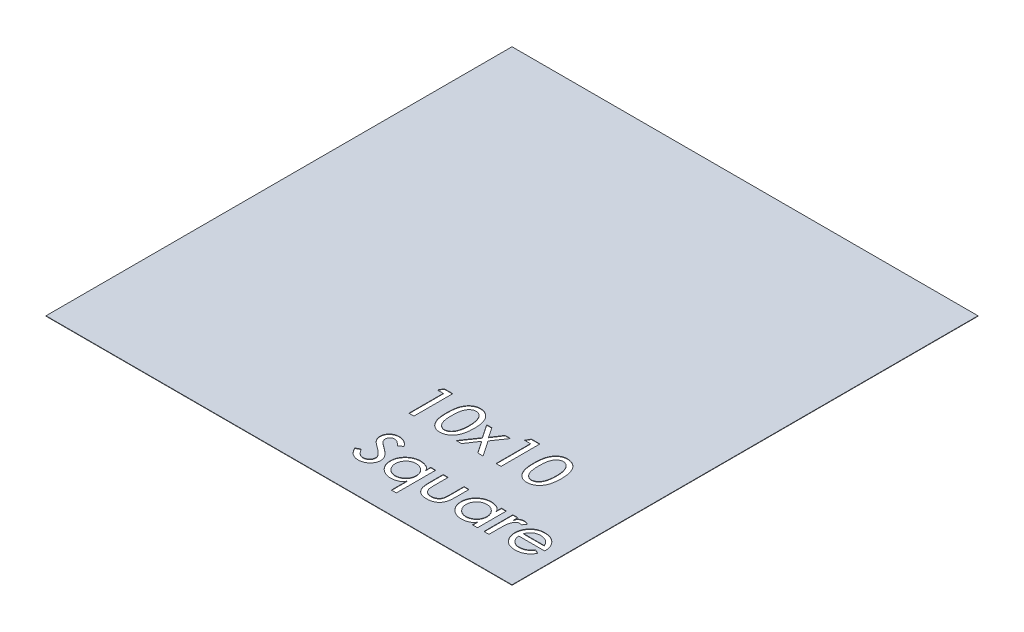
from build123d import *

# Parameters (mm, degrees)
SKETCH1_W           = 3048
SKETCH1_H           = 3048
BOSS_EXTRUDE1_DEPTH = 2.54
CUT_EXTRUDE2_DEPTH  = 2156.262965765


with BuildPart() as part:
    # Sketch1 → Boss-Extrude1 (new body)
    with BuildSketch(Plane(origin=(0, 0, 0), x_dir=(1, 0, 0), z_dir=(0, 1, 0))):
        Rectangle(SKETCH1_W, SKETCH1_H)
    extrude(amount=BOSS_EXTRUDE1_DEPTH)

    # Sketch2 → Cut-Extrude2 (cut, through all)
    with BuildSketch(Plane(origin=(0, 2.54, 0), x_dir=(1, 0, 0), z_dir=(0, 1, 0))):
        Polygon((192.229967949, -635), (247.487179487, -635), (247.487179487, -889), (214.923076923, -889), (214.923076923, -664.307692308), (175.846153846, -664.307692308), align=None)
        with BuildLine():
            add(Edge.make_bspline(
                [(335.41025641, -762.101762821), (335.434499454, -758.064671266), (335.481580391, -750.224481847), (335.988898253, -738.819014353), (336.864059109, -728.113270756), (337.988172455, -718.106933393), (339.543353448, -708.793127329), (341.322802646, -700.167250032), (343.513250124, -692.228240269), (346.07176783, -684.961931683), (348.944468674, -678.239272187), (352.1030169, -671.976054149), (355.527407897, -666.092757879), (359.194513584, -660.591432476), (363.27770374, -655.594639738), (367.537267314, -650.931253922), (372.133140969, -646.69230801), (377.023207575, -642.899023905), (382.081718489, -639.469532347), (387.368486954, -636.578928268), (392.761016337, -634.060936685), (398.328073433, -632.02410003), (404.029294573, -630.441866256), (409.885097662, -629.336904275), (415.867637706, -628.575980313), (419.921893511, -628.516881935), (421.959535256, -628.487179487)],
                knots=[0, 0, 0, 0, 1.622528522, 3.151013738, 4.587225782, 5.939257941, 7.196658267, 8.381214254, 9.47772444, 10.503964975, 11.475138444, 12.414102326, 13.321377868, 14.209997518, 15.068075989, 15.912287155, 16.746865696, 17.577313739, 18.397854368, 19.200328723, 19.996378645, 20.787862277, 21.580050128, 22.371504404, 23.181529048, 24, 24, 24, 24], degree=3))
            add(Edge.make_bspline(
                [(421.959535256, -628.487179487), (424.182379865, -628.545715793), (428.569880309, -628.661256062), (435.081142591, -629.290033177), (441.374097391, -630.560372169), (447.535087093, -632.153426729), (453.464319007, -634.331166799), (459.279243842, -636.835468032), (464.800881522, -640.007399975), (470.217563975, -643.477062648), (475.343569099, -647.478268912), (480.246389626, -651.82585964), (484.773166727, -656.668240282), (489.088909684, -661.838785687), (492.97224572, -667.539995474), (496.669068885, -673.572237826), (499.942369814, -680.085744039), (503.048018162, -686.965290378), (505.717507598, -694.393803895), (508.133650846, -702.32886246), (510.091670609, -710.869327551), (511.715913784, -719.988657253), (512.967623656, -729.702204725), (513.892043404, -739.986896507), (514.374679462, -750.8523479), (514.465954269, -758.285244681), (514.512820513, -762.101762821)],
                knots=[0, 0, 0, 0, 0.875057392, 1.727207867, 2.570264412, 3.399251263, 4.229017074, 5.053828049, 5.887584622, 6.731829445, 7.583639997, 8.443960147, 9.308026848, 10.190032267, 11.091770676, 12.020167189, 12.972467704, 13.958579741, 14.989078804, 16.076606933, 17.221320015, 18.435081626, 19.720875061, 21.074561036, 22.497895074, 24, 24, 24, 24], degree=3))
            add(Edge.make_bspline(
                [(514.512820513, -762.101762821), (514.465463013, -765.901261797), (514.37324234, -773.300139586), (513.897532872, -784.115602525), (512.949153405, -794.344359622), (511.781450929, -804.015120346), (510.143560849, -813.098514052), (508.149241765, -821.599339409), (505.912774184, -829.562291339), (503.178800868, -836.917581253), (500.151500055, -843.789003019), (496.867082848, -850.244267297), (493.249824023, -856.296095073), (489.244593074, -861.878824821), (485.042241958, -867.168122389), (480.460205387, -871.98015549), (475.581989302, -876.406644598), (470.419392417, -880.391216727), (465.031505854, -883.984500453), (459.384530303, -887.01766612), (453.620813027, -889.709902684), (447.611665483, -891.750220043), (441.478899152, -893.491463518), (435.119247395, -894.616213855), (428.591746373, -895.360894553), (424.183459313, -895.461876447), (421.959535256, -895.512820513)],
                knots=[0, 0, 0, 0, 1.496607488, 2.914388442, 4.262485651, 5.541812885, 6.749953981, 7.895567619, 8.980172623, 10.005210728, 10.983286874, 11.936336572, 12.856292636, 13.757107149, 14.640766483, 15.514956722, 16.370989637, 17.232841377, 18.081413197, 18.918442167, 19.755471137, 20.583656588, 21.41504191, 22.264086897, 23.124254193, 24, 24, 24, 24], degree=3))
            add(Edge.make_bspline(
                [(421.959535256, -895.512820513), (419.905560491, -895.477919483), (415.837517, -895.408795505), (409.830397968, -894.730851586), (403.978602063, -893.605701672), (398.299316246, -892.028756099), (392.752636913, -890.026641135), (387.362617971, -887.601358752), (382.164686513, -884.664638351), (377.109237317, -881.364985949), (372.269692781, -877.611874022), (367.761990914, -873.369918107), (363.477751823, -868.740494867), (359.501849262, -863.67368195), (355.746421269, -858.202187744), (352.360958809, -852.274463689), (349.204609268, -845.953819913), (346.278276879, -839.191572131), (343.636074621, -831.870229807), (341.528680346, -823.846557278), (339.541428039, -815.208107911), (338.083070925, -805.867492257), (336.817757639, -795.8951777), (336.083677057, -785.226428111), (335.456348692, -773.896626807), (335.425902192, -766.105467237), (335.41025641, -762.101762821)],
                knots=[0, 0, 0, 0, 0.82614074, 1.636230647, 2.42850654, 3.22151677, 4.005075515, 4.799112676, 5.596456327, 6.404618302, 7.226350817, 8.05679228, 8.892237205, 9.761873943, 10.645770802, 11.559890835, 12.505927976, 13.487073095, 14.523090282, 15.633895838, 16.822583925, 18.088023083, 19.435493537, 20.865857947, 22.389433785, 24, 24, 24, 24], degree=3))
        make_face()
        with BuildLine():
            add(Edge.make_bspline(
                [(367.974358974, -762), (367.98743861, -765.409455164), (368.012759805, -772.009905272), (368.388739511, -781.561046276), (368.924033114, -790.454650129), (369.724746098, -798.688305625), (370.792470777, -806.274255687), (372.056228719, -813.202024179), (373.497102469, -819.484883512), (375.253769584, -825.133157828), (377.198856184, -830.279616325), (379.36154217, -835.017578758), (381.607133386, -839.454384603), (384.1367234, -843.502093196), (386.815621758, -847.216019274), (389.692201635, -850.582025965), (392.663773396, -853.673894723), (396.902776128, -857.107123223), (402.334209169, -860.69655999), (409.076686971, -863.809110794), (415.869971434, -865.863701587), (420.453137659, -866.092048887), (422.72275641, -866.205128205)],
                knots=[0, 0, 0, 0, 1.564601651, 3.028951736, 4.386019676, 5.653114642, 6.824348509, 7.900668805, 8.88431448, 9.780488761, 10.613163047, 11.407444027, 12.169849642, 12.89344098, 13.595615509, 14.26934431, 14.924332585, 15.560171042, 16.769153194, 17.901006317, 18.960562374, 20, 20, 20, 20], degree=3))
            add(Edge.make_bspline(
                [(422.72275641, -866.205128205), (425.294691338, -866.070555647), (430.422555767, -865.802247989), (437.974666574, -863.848628994), (445.215897442, -860.569754731), (450.953518018, -856.865368), (455.288522051, -853.26239966), (458.419180715, -850.195194667), (461.30474608, -846.770871878), (464.028813927, -843.04157547), (466.491919134, -838.946299362), (468.866919371, -834.577991003), (470.934809126, -829.831847781), (472.12993962, -826.524521342), (472.739182692, -824.838541667)],
                knots=[0, 0, 0, 0, 1.331887272, 2.655486065, 4.012646414, 5.436183829, 6.178803566, 6.930724497, 7.703763371, 8.496530827, 9.320959298, 10.178042319, 11.071218497, 12, 12, 12, 12], degree=3))
            add(Edge.make_bspline(
                [(472.739182692, -824.838541667), (473.473180057, -822.623403692), (474.969484539, -818.107691458), (476.844148382, -811.077026858), (478.39613926, -803.699746491), (479.732489903, -796.015138475), (480.747182931, -787.984488074), (481.448548978, -779.615530495), (481.850862649, -770.908214314), (481.915736939, -765.002411801), (481.948717949, -762)],
                knots=[0, 0, 0, 0, 0.877617242, 1.789083553, 2.735016418, 3.71249782, 4.722174671, 5.778575778, 6.870664861, 8, 8, 8, 8], degree=3))
            add(Edge.make_bspline(
                [(481.948717949, -762), (481.940824192, -758.997280752), (481.925430046, -753.14147552), (481.467899761, -744.575865142), (480.914565601, -736.422547144), (479.959961757, -728.708297512), (478.891610435, -721.394618292), (477.426207668, -714.533217135), (475.854479089, -708.055596248), (473.890932305, -702.041760343), (471.7441899, -696.43104798), (469.479993242, -691.20478329), (467.031835204, -686.3587844), (464.334543708, -681.953856126), (461.48766081, -677.917336047), (458.480565095, -674.273500161), (455.268448423, -671.042858675), (450.777800071, -667.400241418), (444.988790674, -663.609066935), (437.750117878, -660.206687591), (430.275463673, -658.200882566), (425.227184971, -657.929502323), (422.72275641, -657.794871795)],
                knots=[0, 0, 0, 0, 1.353201578, 2.638969622, 3.865559904, 5.035676431, 6.141732754, 7.195734042, 8.19695873, 9.144657206, 10.044788335, 10.904062871, 11.710933862, 12.489720227, 13.229995877, 13.935715626, 14.616825307, 15.279494989, 16.538995736, 17.725922936, 18.871840505, 20, 20, 20, 20], degree=3))
            add(Edge.make_bspline(
                [(422.72275641, -657.794871795), (420.453792121, -657.910160565), (415.855591731, -658.143800588), (409.051997557, -660.169856602), (402.333791895, -663.307086837), (396.938755, -666.899008097), (392.734809184, -670.328595555), (389.722668845, -673.350139968), (386.939829898, -676.735166641), (384.254293862, -680.419198111), (381.802100787, -684.493529787), (379.420372339, -688.883837768), (377.321903629, -693.662657712), (375.348415342, -698.813058996), (373.610250865, -704.471656143), (372.107100933, -710.744926437), (370.76385473, -717.665035115), (369.795781672, -725.266294688), (368.981986472, -733.512458745), (368.372948449, -742.420001113), (368.017344324, -751.990351639), (367.989000134, -758.590632342), (367.974358974, -762)],
                knots=[0, 0, 0, 0, 1.039778295, 2.107176824, 3.232337611, 4.43520669, 5.071253539, 5.720927637, 6.389866065, 7.081397607, 7.811854436, 8.571243718, 9.372887587, 10.205834777, 11.102302774, 12.088086757, 13.166194718, 14.33675119, 15.604261439, 16.970055543, 18.43488556, 20, 20, 20, 20], degree=3))
        make_face(mode=Mode.SUBTRACT)
        Polygon((534.051282051, -700.128205128), (568.650641026, -700.128205128), (611.899839744, -765.358173077), (655.098157051, -700.128205128), (690.358974359, -700.128205128), (630.624198718, -787.695112179), (700.128205128, -889), (664.81650641, -889), (611.848958333, -809.981169872), (558.932291667, -889), (524.282051282, -889), (593.836939103, -787.74599359), align=None)
        Polygon((762.101762821, -635), (817.358974359, -635), (817.358974359, -889), (784.794871795, -889), (784.794871795, -664.307692308), (745.717948718, -664.307692308), align=None)
        with BuildLine():
            add(Edge.make_bspline(
                [(905.282051282, -762.101762821), (905.306294326, -758.064671266), (905.353375263, -750.224481847), (905.860693125, -738.819014353), (906.735853981, -728.113270756), (907.859967327, -718.106933393), (909.41514832, -708.793127329), (911.194597517, -700.167250032), (913.385044996, -692.228240269), (915.943562701, -684.961931683), (918.816263546, -678.239272187), (921.974811772, -671.976054149), (925.399202769, -666.092757879), (929.066308455, -660.591432476), (933.149498612, -655.594639738), (937.409062186, -650.931253922), (942.004935841, -646.69230801), (946.895002446, -642.899023905), (951.953513361, -639.469532347), (957.240281826, -636.578928268), (962.632811208, -634.060936685), (968.199868305, -632.02410003), (973.901089444, -630.441866256), (979.756892534, -629.336904275), (985.739432578, -628.575980313), (989.793688383, -628.516881935), (991.831330128, -628.487179487)],
                knots=[0, 0, 0, 0, 1.622528522, 3.151013738, 4.587225782, 5.939257941, 7.196658267, 8.381214254, 9.47772444, 10.503964975, 11.475138444, 12.414102326, 13.321377868, 14.209997518, 15.068075989, 15.912287155, 16.746865696, 17.577313739, 18.397854368, 19.200328723, 19.996378645, 20.787862277, 21.580050128, 22.371504404, 23.181529048, 24, 24, 24, 24], degree=3))
            add(Edge.make_bspline(
                [(991.831330128, -628.487179487), (994.054174736, -628.545715793), (998.441675181, -628.661256062), (1004.952937463, -629.290033177), (1011.245892263, -630.560372169), (1017.406881965, -632.153426729), (1023.336113879, -634.331166799), (1029.151038714, -636.835468032), (1034.672676394, -640.007399975), (1040.089358847, -643.477062648), (1045.215363971, -647.478268912), (1050.118184498, -651.82585964), (1054.644961599, -656.668240282), (1058.960704556, -661.838785687), (1062.844040591, -667.539995474), (1066.540863756, -673.572237826), (1069.814164686, -680.085744039), (1072.919813034, -686.965290378), (1075.58930247, -694.393803895), (1078.005445718, -702.32886246), (1079.963465481, -710.869327551), (1081.587708656, -719.988657253), (1082.839418528, -729.702204725), (1083.763838276, -739.986896507), (1084.246474333, -750.8523479), (1084.33774914, -758.285244681), (1084.384615385, -762.101762821)],
                knots=[0, 0, 0, 0, 0.875057392, 1.727207867, 2.570264412, 3.399251263, 4.229017074, 5.053828049, 5.887584622, 6.731829445, 7.583639997, 8.443960147, 9.308026848, 10.190032267, 11.091770676, 12.020167189, 12.972467704, 13.958579741, 14.989078804, 16.076606933, 17.221320015, 18.435081626, 19.720875061, 21.074561036, 22.497895074, 24, 24, 24, 24], degree=3))
            add(Edge.make_bspline(
                [(1084.384615385, -762.101762821), (1084.337257885, -765.901261797), (1084.245037212, -773.300139586), (1083.769327744, -784.115602525), (1082.820948276, -794.344359622), (1081.653245801, -804.015120346), (1080.015355721, -813.098514052), (1078.021036637, -821.599339409), (1075.784569055, -829.562291339), (1073.05059574, -836.917581253), (1070.023294927, -843.789003019), (1066.73887772, -850.244267297), (1063.121618895, -856.296095073), (1059.116387945, -861.878824821), (1054.91403683, -867.168122389), (1050.332000258, -871.98015549), (1045.453784174, -876.406644598), (1040.291187289, -880.391216727), (1034.903300726, -883.984500453), (1029.256325175, -887.01766612), (1023.492607898, -889.709902684), (1017.483460355, -891.750220043), (1011.350694023, -893.491463518), (1004.991042267, -894.616213855), (998.463541244, -895.360894553), (994.055254185, -895.461876447), (991.831330128, -895.512820513)],
                knots=[0, 0, 0, 0, 1.496607488, 2.914388442, 4.262485651, 5.541812885, 6.749953981, 7.895567619, 8.980172623, 10.005210728, 10.983286874, 11.936336572, 12.856292636, 13.757107149, 14.640766483, 15.514956722, 16.370989637, 17.232841377, 18.081413197, 18.918442167, 19.755471137, 20.583656588, 21.41504191, 22.264086897, 23.124254193, 24, 24, 24, 24], degree=3))
            add(Edge.make_bspline(
                [(991.831330128, -895.512820513), (989.777355363, -895.477919483), (985.709311872, -895.408795505), (979.70219284, -894.730851586), (973.850396935, -893.605701672), (968.171111118, -892.028756099), (962.624431785, -890.026641135), (957.234412843, -887.601358752), (952.036481385, -884.664638351), (946.981032189, -881.364985949), (942.141487653, -877.611874022), (937.633785785, -873.369918107), (933.349546695, -868.740494867), (929.373644134, -863.67368195), (925.61821614, -858.202187744), (922.23275368, -852.274463689), (919.07640414, -845.953819913), (916.15007175, -839.191572131), (913.507869493, -831.870229807), (911.400475218, -823.846557278), (909.413222911, -815.208107911), (907.954865797, -805.867492257), (906.689552511, -795.8951777), (905.955471928, -785.226428111), (905.328143564, -773.896626807), (905.297697064, -766.105467237), (905.282051282, -762.101762821)],
                knots=[0, 0, 0, 0, 0.82614074, 1.636230647, 2.42850654, 3.22151677, 4.005075515, 4.799112676, 5.596456327, 6.404618302, 7.226350817, 8.05679228, 8.892237205, 9.761873943, 10.645770802, 11.559890835, 12.505927976, 13.487073095, 14.523090282, 15.633895838, 16.822583925, 18.088023083, 19.435493537, 20.865857947, 22.389433785, 24, 24, 24, 24], degree=3))
        make_face()
        with BuildLine():
            add(Edge.make_bspline(
                [(937.846153846, -762), (937.859233481, -765.409455164), (937.884554677, -772.009905272), (938.260534383, -781.561046276), (938.795827985, -790.454650129), (939.59654097, -798.688305625), (940.664265649, -806.274255687), (941.928023591, -813.202024179), (943.368897341, -819.484883512), (945.125564456, -825.133157828), (947.070651056, -830.279616325), (949.233337042, -835.017578758), (951.478928258, -839.454384603), (954.008518271, -843.502093196), (956.68741663, -847.216019274), (959.563996507, -850.582025965), (962.535568268, -853.673894723), (966.774570999, -857.107123223), (972.20600404, -860.69655999), (978.948481842, -863.809110794), (985.741766306, -865.863701587), (990.324932531, -866.092048887), (992.594551282, -866.205128205)],
                knots=[0, 0, 0, 0, 1.564601651, 3.028951736, 4.386019676, 5.653114642, 6.824348509, 7.900668805, 8.88431448, 9.780488761, 10.613163047, 11.407444027, 12.169849642, 12.89344098, 13.595615509, 14.26934431, 14.924332585, 15.560171042, 16.769153194, 17.901006317, 18.960562374, 20, 20, 20, 20], degree=3))
            add(Edge.make_bspline(
                [(992.594551282, -866.205128205), (995.16648621, -866.070555647), (1000.294350639, -865.802247989), (1007.846461446, -863.848628994), (1015.087692314, -860.569754731), (1020.825312889, -856.865368), (1025.160316922, -853.26239966), (1028.290975587, -850.195194667), (1031.176540952, -846.770871878), (1033.900608799, -843.04157547), (1036.363714006, -838.946299362), (1038.738714242, -834.577991003), (1040.806603998, -829.831847781), (1042.001734492, -826.524521342), (1042.610977564, -824.838541667)],
                knots=[0, 0, 0, 0, 1.331887272, 2.655486065, 4.012646414, 5.436183829, 6.178803566, 6.930724497, 7.703763371, 8.496530827, 9.320959298, 10.178042319, 11.071218497, 12, 12, 12, 12], degree=3))
            add(Edge.make_bspline(
                [(1042.610977564, -824.838541667), (1043.344974929, -822.623403692), (1044.841279411, -818.107691458), (1046.715943254, -811.077026858), (1048.267934131, -803.699746491), (1049.604284775, -796.015138475), (1050.618977802, -787.984488074), (1051.32034385, -779.615530495), (1051.722657521, -770.908214314), (1051.78753181, -765.002411801), (1051.820512821, -762)],
                knots=[0, 0, 0, 0, 0.877617242, 1.789083553, 2.735016418, 3.71249782, 4.722174671, 5.778575778, 6.870664861, 8, 8, 8, 8], degree=3))
            add(Edge.make_bspline(
                [(1051.820512821, -762), (1051.812619064, -758.997280752), (1051.797224918, -753.14147552), (1051.339694633, -744.575865142), (1050.786360473, -736.422547144), (1049.831756629, -728.708297512), (1048.763405307, -721.394618292), (1047.29800254, -714.533217135), (1045.726273961, -708.055596248), (1043.762727176, -702.041760343), (1041.615984772, -696.43104798), (1039.351788114, -691.20478329), (1036.903630076, -686.3587844), (1034.206338579, -681.953856126), (1031.359455681, -677.917336047), (1028.352359966, -674.273500161), (1025.140243294, -671.042858675), (1020.649594943, -667.400241418), (1014.860585545, -663.609066935), (1007.62191275, -660.206687591), (1000.147258545, -658.200882566), (995.098979843, -657.929502323), (992.594551282, -657.794871795)],
                knots=[0, 0, 0, 0, 1.353201578, 2.638969622, 3.865559904, 5.035676431, 6.141732754, 7.195734042, 8.19695873, 9.144657206, 10.044788335, 10.904062871, 11.710933862, 12.489720227, 13.229995877, 13.935715626, 14.616825307, 15.279494989, 16.538995736, 17.725922936, 18.871840505, 20, 20, 20, 20], degree=3))
            add(Edge.make_bspline(
                [(992.594551282, -657.794871795), (990.325586993, -657.910160565), (985.727386603, -658.143800588), (978.923792429, -660.169856602), (972.205586767, -663.307086837), (966.810549872, -666.899008097), (962.606604056, -670.328595555), (959.594463717, -673.350139968), (956.81162477, -676.735166641), (954.126088734, -680.419198111), (951.673895659, -684.493529787), (949.292167211, -688.883837768), (947.193698501, -693.662657712), (945.220210214, -698.813058996), (943.482045737, -704.471656143), (941.978895805, -710.744926437), (940.635649602, -717.665035115), (939.667576544, -725.266294688), (938.853781344, -733.512458745), (938.244743321, -742.420001113), (937.889139196, -751.990351639), (937.860795006, -758.590632342), (937.846153846, -762)],
                knots=[0, 0, 0, 0, 1.039778295, 2.107176824, 3.232337611, 4.43520669, 5.071253539, 5.720927637, 6.389866065, 7.081397607, 7.811854436, 8.571243718, 9.372887587, 10.205834777, 11.102302774, 12.088086757, 13.166194718, 14.33675119, 15.604261439, 16.970055543, 18.43488556, 20, 20, 20, 20], degree=3))
        make_face(mode=Mode.SUBTRACT)
        with BuildLine():
            Line((234.461538462, -1262.960737179), (262.141025641, -1248.205128205))
            add(Edge.make_bspline(
                [(262.141025641, -1248.205128205), (264.158185607, -1251.546398089), (268.013537115, -1257.93249047), (274.344219973, -1266.535315094), (280.638633408, -1273.871263561), (286.958910722, -1279.932928818), (293.392845403, -1284.622942612), (299.874754153, -1288.012513536), (306.445205901, -1290.142971553), (310.887700459, -1290.408048888), (313.073317308, -1290.538461538)],
                knots=[0, 0, 0, 0, 1.354943589, 2.589672558, 3.704607527, 4.708856974, 5.624398268, 6.459549776, 7.242129862, 8, 8, 8, 8], degree=3))
            add(Edge.make_bspline(
                [(313.073317308, -1290.538461538), (315.113708245, -1290.472874872), (319.155135723, -1290.342966555), (325.093225629, -1289.216341415), (330.842868946, -1287.49976194), (336.304434977, -1285.055390823), (341.350171763, -1282.060736386), (345.804448209, -1278.498723427), (349.583777583, -1274.465999825), (352.698821135, -1270.017272237), (355.140578133, -1265.26738581), (356.938086057, -1260.351122357), (357.993043867, -1255.254316292), (358.133918035, -1251.822487768), (358.205128205, -1250.087740385)],
                knots=[0, 0, 0, 0, 1.0888553, 2.156709112, 3.216967111, 4.287545289, 5.343926646, 6.34269433, 7.323221176, 8.28571565, 9.233736345, 10.167849744, 11.073870434, 12, 12, 12, 12], degree=3))
            add(Edge.make_bspline(
                [(358.205128205, -1250.087740385), (358.105356096, -1248.110675936), (357.903739482, -1244.115480853), (356.285515649, -1238.18057087), (353.655606594, -1232.303731197), (351.22288143, -1228.634449375), (349.962339744, -1226.733173077)],
                knots=[0, 0, 0, 0, 0.941861274, 1.903286225, 2.913566088, 4, 4, 4, 4], degree=3))
            add(Edge.make_bspline(
                [(349.962339744, -1226.733173077), (348.872344532, -1225.349181969), (346.577812047, -1222.435763157), (342.693819374, -1218.049565808), (338.149038165, -1213.474111236), (332.950840815, -1208.730040935), (327.190595916, -1203.7110545), (320.770456365, -1198.546870194), (313.735807945, -1193.150212427), (308.806121612, -1189.529712347), (306.255208333, -1187.65625)],
                knots=[0, 0, 0, 0, 0.718593868, 1.512701116, 2.388487339, 3.348232282, 4.383172848, 5.504845107, 6.708858268, 8, 8, 8, 8], degree=3))
            add(Edge.make_bspline(
                [(306.255208333, -1187.65625), (303.653944479, -1185.765215278), (298.66284756, -1182.136849182), (291.630827818, -1176.817647653), (285.325937722, -1171.913049104), (279.796525601, -1167.419220086), (275.041963039, -1163.297102215), (271.07226587, -1159.563610372), (267.767929768, -1156.321201394), (265.992273738, -1154.139556461), (265.193910256, -1153.158653846)],
                knots=[0, 0, 0, 0, 1.435833971, 2.754963323, 3.936484598, 5.002077172, 5.935979083, 6.744956812, 7.435712417, 8, 8, 8, 8], degree=3))
            add(Edge.make_bspline(
                [(265.193910256, -1153.158653846), (264.028407468, -1151.65271081), (261.738683477, -1148.694164565), (258.839813641, -1143.948464808), (256.345401069, -1139.14065488), (254.290882417, -1134.226217496), (252.698754217, -1129.22085258), (251.603445289, -1124.107006677), (250.830833399, -1118.904993044), (250.77277571, -1115.390537211), (250.743589744, -1113.623798077)],
                knots=[0, 0, 0, 0, 1.064105702, 2.090521257, 3.104283852, 4.09061442, 5.065433238, 6.036507983, 7.012940167, 8, 8, 8, 8], degree=3))
            add(Edge.make_bspline(
                [(250.743589744, -1113.623798077), (250.835499884, -1110.868597864), (251.017475237, -1105.413503022), (252.643675739, -1097.449881741), (255.278961613, -1089.861972942), (258.876098834, -1082.688994201), (263.469577488, -1076.064463934), (268.933333713, -1070.119209085), (275.296930157, -1064.980090066), (282.390575245, -1060.64983834), (290.036688303, -1057.137975399), (298.089837241, -1054.634880321), (306.452395551, -1053.117415446), (312.134208665, -1052.920213748), (315.006810897, -1052.820512821)],
                knots=[0, 0, 0, 0, 1.004530234, 1.988896367, 2.951881425, 3.928924249, 4.907494835, 5.884204368, 6.865296418, 7.88218147, 8.909671266, 9.927572845, 10.952225504, 12, 12, 12, 12], degree=3))
            add(Edge.make_bspline(
                [(315.006810897, -1052.820512821), (318.268486791, -1052.937259924), (324.728251703, -1053.168478127), (334.250552451, -1054.735406578), (343.356211427, -1057.556553646), (350.689814806, -1060.670576085), (356.386683157, -1063.854418857), (360.695341237, -1066.729973978), (365.111493539, -1069.984283652), (369.495267438, -1073.779572828), (374.017518647, -1077.932211139), (378.446671579, -1082.66792645), (383.063023859, -1087.715309001), (386.005317875, -1091.355353253), (387.512820513, -1093.220352564)],
                knots=[0, 0, 0, 0, 1.360590218, 2.69465552, 4.010645498, 5.328858611, 6.009843139, 6.729980544, 7.488405022, 8.296451933, 9.147430815, 10.048128915, 10.999946711, 12, 12, 12, 12], degree=3))
            Line((387.512820513, -1093.220352564), (360.952724359, -1111.435897436))
            add(Edge.make_bspline(
                [(360.952724359, -1111.435897436), (359.566624871, -1109.955918328), (356.90150344, -1107.11028995), (352.981165148, -1103.07475406), (349.271990585, -1099.453149041), (345.762722978, -1096.262042545), (342.532017543, -1093.444525261), (339.48909445, -1091.095604449), (336.729109735, -1089.0768137), (333.278884028, -1087.075969304), (329.049167625, -1085.094362834), (323.843379223, -1083.311371538), (318.382731388, -1082.358472299), (314.687834509, -1082.205553391), (312.818910256, -1082.128205128)],
                knots=[0, 0, 0, 0, 1.253377364, 2.409930098, 3.477532466, 4.457083962, 5.341772995, 6.126101147, 6.832963523, 7.453284126, 8.588253012, 9.715448048, 10.844445545, 12, 12, 12, 12], degree=3))
            add(Edge.make_bspline(
                [(312.818910256, -1082.128205128), (310.824033143, -1082.221429891), (306.945829155, -1082.402666441), (301.374992524, -1083.954652574), (296.254046908, -1086.403633751), (291.735937151, -1089.86959791), (287.980625676, -1094.159533529), (285.226555292, -1099.184649686), (283.614797417, -1104.911437536), (283.41294967, -1108.932162391), (283.307692308, -1111.028846154)],
                knots=[0, 0, 0, 0, 1.033513523, 2.009234674, 2.977584268, 3.963375862, 4.942860848, 5.915719707, 6.913112236, 8, 8, 8, 8], degree=3))
            add(Edge.make_bspline(
                [(283.307692308, -1111.028846154), (283.34870386, -1112.387429704), (283.430627767, -1115.101310717), (284.032381993, -1119.121340138), (285.144724414, -1123.00564225), (286.554287054, -1126.83608881), (288.527191761, -1130.59115741), (291.039803688, -1134.276777567), (294.022505968, -1137.999131814), (296.311620295, -1140.339183026), (297.503605769, -1141.557692308)],
                knots=[0, 0, 0, 0, 0.940834015, 1.879392378, 2.805520916, 3.734846727, 4.701501436, 5.734192883, 6.820151034, 8, 8, 8, 8], degree=3))
            add(Edge.make_bspline(
                [(297.503605769, -1141.557692308), (298.10715878, -1142.125485233), (299.492439496, -1143.428689057), (302.033193105, -1145.424280655), (305.128705328, -1147.926219436), (308.821890983, -1150.893669426), (313.234190335, -1154.165523205), (318.202465117, -1157.960367602), (323.852512439, -1162.10736301), (327.828466549, -1165.014688182), (329.915064103, -1166.540464744)],
                knots=[0, 0, 0, 0, 0.485581606, 1.114511607, 1.892484918, 2.819534315, 3.891398566, 5.11240712, 6.484579029, 8, 8, 8, 8], degree=3))
            add(Edge.make_bspline(
                [(329.915064103, -1166.540464744), (332.757817987, -1168.612541339), (338.257224377, -1172.621045675), (346.069319953, -1178.667346951), (353.114726819, -1184.594209411), (359.571569767, -1190.194858661), (365.221489313, -1195.70423085), (370.17034589, -1201.009046765), (374.480287798, -1206.057527282), (379.083357442, -1212.494198741), (383.685504356, -1220.429508765), (387.800774873, -1230.020821949), (390.256485822, -1239.687799271), (390.599787799, -1246.139944796), (390.769230769, -1249.324519231)],
                knots=[0, 0, 0, 0, 1.186540699, 2.295404303, 3.331123753, 4.291760032, 5.17774712, 5.991329992, 6.738459906, 7.414799035, 8.65800623, 9.82461674, 10.926299804, 12, 12, 12, 12], degree=3))
            add(Edge.make_bspline(
                [(390.769230769, -1249.324519231), (390.697133405, -1251.583928367), (390.553834382, -1256.074676763), (389.514876927, -1262.714535786), (387.786143112, -1269.168250964), (385.299046315, -1275.4085705), (382.196904518, -1281.494061362), (378.350456189, -1287.371520396), (373.772238728, -1293.018299427), (368.655399559, -1298.468519892), (362.997467349, -1303.477485007), (356.929977377, -1307.886034919), (350.471454165, -1311.568912989), (343.671666442, -1314.556929239), (336.57051214, -1316.991791382), (329.09781549, -1318.659468304), (321.290535511, -1319.622076035), (315.976221877, -1319.77067417), (313.276842949, -1319.846153846)],
                knots=[0, 0, 0, 0, 0.932646097, 1.853705421, 2.767602683, 3.685675702, 4.622099834, 5.5835355, 6.579838097, 7.620108014, 8.666886363, 9.695041649, 10.711275682, 11.730160242, 12.757671447, 13.80585424, 14.885494678, 16, 16, 16, 16], degree=3))
            add(Edge.make_bspline(
                [(313.276842949, -1319.846153846), (311.308425165, -1319.802432776), (307.43145607, -1319.716320348), (301.675794576, -1319.170093827), (296.074818951, -1318.120251926), (290.597820989, -1316.762912087), (285.241382386, -1315.034523081), (280.074532798, -1312.823596679), (275.011232221, -1310.284042144), (270.080526175, -1307.31048685), (265.276127039, -1303.828687745), (260.570732096, -1299.787003787), (255.991673799, -1295.114387198), (251.460457366, -1289.871545086), (247.036946164, -1283.999506354), (242.731467371, -1277.529148055), (238.489047699, -1270.481335251), (235.830502591, -1265.517014119), (234.461538462, -1262.960737179)],
                knots=[0, 0, 0, 0, 0.916943493, 1.805999526, 2.689245248, 3.568702553, 4.433092864, 5.307568578, 6.183755457, 7.069823058, 7.986358083, 8.944343836, 9.955449961, 11.030835633, 12.170024038, 13.377301724, 14.649494474, 16, 16, 16, 16], degree=3))
        make_face()
        with BuildLine():
            Line((625.230769231, -1124.461538462), (625.230769231, -1381.717948718))
            Line((625.230769231, -1381.717948718), (592.666666667, -1381.717948718))
            Line((592.666666667, -1381.717948718), (592.666666667, -1280.362179487))
            add(Edge.make_bspline(
                [(592.666666667, -1280.362179487), (592.084087666, -1281.715647893), (590.918002851, -1284.424737911), (588.649278947, -1288.268469531), (585.931478741, -1291.880803438), (582.811957165, -1295.32250582), (579.225055109, -1298.510779547), (575.252142771, -1301.546611818), (570.779514638, -1304.258145053), (564.366407785, -1307.735108889), (555.705834815, -1311.236522563), (544.804394172, -1314.391935342), (533.334430119, -1316.247917244), (525.509817721, -1316.474583713), (521.534455128, -1316.58974359)],
                knots=[0, 0, 0, 0, 0.628488499, 1.257976848, 1.899382682, 2.555331049, 3.237097153, 3.945109064, 4.686389084, 5.466961566, 7.057390369, 8.661354283, 10.303771916, 12, 12, 12, 12], degree=3))
            add(Edge.make_bspline(
                [(521.534455128, -1316.58974359), (518.205944024, -1316.499650287), (511.6409795, -1316.32195542), (501.973314398, -1314.975080742), (492.687795602, -1312.733666254), (483.762175907, -1309.619004495), (475.221479057, -1305.570965969), (467.061961031, -1300.616146087), (459.297180932, -1294.762801465), (451.969688307, -1288.15931175), (445.303763489, -1280.87505368), (439.403169707, -1273.131149886), (434.46430355, -1264.942135438), (430.344798256, -1256.405876886), (427.179816705, -1247.446673912), (424.950989669, -1238.101072382), (423.597956559, -1228.367049689), (423.422505927, -1221.751147105), (423.333333333, -1218.388621795)],
                knots=[0, 0, 0, 0, 1.033362466, 2.038144899, 3.024299931, 3.995390054, 4.968377829, 5.953815345, 6.954489863, 7.983669828, 9.012499361, 10.016342745, 11.001780262, 11.977031811, 12.954839801, 13.946114836, 14.956115094, 16, 16, 16, 16], degree=3))
            add(Edge.make_bspline(
                [(423.333333333, -1218.388621795), (423.417968862, -1215.110015826), (423.585369188, -1208.625272143), (425.016673084, -1199.103707648), (427.21822582, -1189.910675248), (430.476549, -1181.133166373), (434.552984216, -1172.680365989), (439.578740904, -1164.605177213), (445.521649483, -1156.897173938), (452.277356753, -1149.632281433), (459.700744621, -1143.045359367), (467.519443786, -1137.175962592), (475.73170637, -1132.223621128), (484.322723, -1128.175479626), (493.299058745, -1125.060677114), (502.619129634, -1122.825587803), (512.319072723, -1121.469555447), (518.901218115, -1121.294238438), (522.246794872, -1121.205128205)],
                knots=[0, 0, 0, 0, 1.020618803, 2.018678488, 2.992382782, 3.959992561, 4.92863996, 5.910776111, 6.916619819, 7.955690666, 8.995808327, 10.003702857, 10.996604865, 11.977276721, 12.956254092, 13.950490127, 14.958273908, 16, 16, 16, 16], degree=3))
            add(Edge.make_bspline(
                [(522.246794872, -1121.205128205), (526.291074528, -1121.315309728), (534.219204391, -1121.531302066), (545.800110683, -1123.440100272), (556.832676938, -1126.408001786), (565.486000556, -1129.97031912), (571.930082913, -1133.366729327), (576.293000851, -1136.149228021), (580.227779103, -1139.162687772), (583.625073512, -1142.486559398), (586.620546884, -1146.011913088), (589.122156649, -1149.806470549), (591.197891143, -1153.84482643), (592.175266869, -1156.706336936), (592.666666667, -1158.145032051)],
                knots=[0, 0, 0, 0, 1.716657277, 3.365217784, 4.971270217, 6.560530054, 7.327512158, 8.062889103, 8.755980397, 9.428436733, 10.077769018, 10.717114698, 11.354997714, 12, 12, 12, 12], degree=3))
            Line((592.666666667, -1158.145032051), (592.666666667, -1124.461538462))
            Line((592.666666667, -1124.461538462), (625.230769231, -1124.461538462))
        make_face()
        with BuildLine():
            add(Edge.make_bspline(
                [(522.755608974, -1150.512820513), (519.881871501, -1150.604483556), (514.191667934, -1150.785982868), (505.82436549, -1152.426084052), (497.754389193, -1155.093524007), (490.049454039, -1158.81394633), (482.769467148, -1163.470971237), (476.219367416, -1169.259774539), (470.329301341, -1175.973143164), (465.235904985, -1183.564740863), (461.07737378, -1191.774890701), (458.091299792, -1200.451862344), (456.25641651, -1209.441140902), (456.017526639, -1215.564696736), (455.897435897, -1218.643028846)],
                knots=[0, 0, 0, 0, 0.974506396, 1.929591628, 2.881601621, 3.852224148, 4.826169364, 5.805204388, 6.808608303, 7.849533547, 8.899838684, 9.922896291, 10.95583298, 12, 12, 12, 12], degree=3))
            add(Edge.make_bspline(
                [(455.897435897, -1218.643028846), (456.016290579, -1221.721588791), (456.25207906, -1227.828954237), (458.105360943, -1236.835921812), (461.117617479, -1245.551218641), (465.351254536, -1253.833291166), (470.470539589, -1261.491110601), (476.367678458, -1268.302799793), (482.986560547, -1274.089770273), (490.217284529, -1278.902460617), (497.959843191, -1282.567025483), (505.932637114, -1285.323898632), (514.176809609, -1286.938909539), (519.746806219, -1287.167116808), (522.552083333, -1287.282051282)],
                knots=[0, 0, 0, 0, 1.043890897, 2.07091085, 3.106456601, 4.164214128, 5.217626504, 6.225096955, 7.211993606, 8.19198703, 9.162352883, 10.110485497, 11.048363551, 12, 12, 12, 12], degree=3))
            add(Edge.make_bspline(
                [(522.552083333, -1287.282051282), (525.646431533, -1287.17633124), (531.779716305, -1286.966784324), (540.84942604, -1285.222592092), (549.617064092, -1282.347652336), (558.057368593, -1278.450234366), (565.868530051, -1273.560704058), (572.889831431, -1267.84988641), (578.827626521, -1261.236314704), (583.857463232, -1253.956473706), (587.751086011, -1245.980175965), (590.642144302, -1237.530031754), (592.35951952, -1228.566301345), (592.562928554, -1222.4326397), (592.666666667, -1219.304487179)],
                knots=[0, 0, 0, 0, 1.022399401, 2.026490321, 3.040784809, 4.066867991, 5.092169477, 6.080081507, 7.048709079, 8.02078757, 8.996288655, 9.973335651, 10.966406111, 12, 12, 12, 12], degree=3))
            add(Edge.make_bspline(
                [(592.666666667, -1219.304487179), (592.61372735, -1216.909715203), (592.509276716, -1212.184768401), (591.513197044, -1205.266212055), (589.9246159, -1198.642367361), (587.766221395, -1192.308509533), (584.854299424, -1186.318811419), (581.420024091, -1180.584356295), (577.226846061, -1175.229558072), (572.542509978, -1170.175094792), (567.38339547, -1165.571382329), (561.889728267, -1161.53083197), (556.063039872, -1158.146160877), (549.975543428, -1155.328810651), (543.56126274, -1153.21685495), (536.900406421, -1151.596024363), (529.921169204, -1150.688417713), (525.16645919, -1150.571900129), (522.755608974, -1150.512820513)],
                knots=[0, 0, 0, 0, 1.049538253, 2.070766012, 3.057425551, 4.033461752, 4.998098599, 5.972518539, 6.958729546, 7.974309418, 8.990869055, 9.985984514, 10.959183395, 11.940869635, 12.921541271, 13.915433273, 14.94303162, 16, 16, 16, 16], degree=3))
        make_face(mode=Mode.SUBTRACT)
        with BuildLine():
            Line((674.076923077, -1124.461538462), (706.641025641, -1124.461538462))
            Line((706.641025641, -1124.461538462), (706.641025641, -1212.130208333))
            add(Edge.make_bspline(
                [(706.641025641, -1212.130208333), (706.650583168, -1214.606478203), (706.668914665, -1219.356005096), (706.812564394, -1226.175778727), (707.086702672, -1232.348106547), (707.341462694, -1237.884758433), (707.838132858, -1242.765022189), (708.291395511, -1247.036559334), (708.950926723, -1250.652028014), (709.497462074, -1252.820679749), (709.744791667, -1253.802083333)],
                knots=[0, 0, 0, 0, 1.418944939, 2.721560048, 3.90822129, 4.959445687, 5.896519748, 6.718644391, 7.420134194, 8, 8, 8, 8], degree=3))
            add(Edge.make_bspline(
                [(709.744791667, -1253.802083333), (710.674613225, -1256.436200259), (712.471902258, -1261.527789521), (716.564019082, -1268.372664325), (721.503269601, -1274.263587539), (727.45878386, -1279.012776011), (734.101840445, -1282.77541512), (741.423684234, -1285.308221556), (749.249139589, -1287.049537945), (754.679932592, -1287.203109836), (757.471554487, -1287.282051282)],
                knots=[0, 0, 0, 0, 1.064698082, 2.057997224, 3.027713519, 3.985869738, 4.951769774, 5.929245647, 6.93555818, 8, 8, 8, 8], degree=3))
            add(Edge.make_bspline(
                [(757.471554487, -1287.282051282), (760.515472255, -1287.179085728), (766.395474081, -1286.98018494), (774.850729904, -1285.323206362), (782.588030754, -1282.597982719), (789.466943092, -1278.663174888), (795.562532034, -1273.983057003), (800.567316885, -1268.43736334), (804.753805956, -1262.34173974), (806.537998178, -1257.77996674), (807.437099359, -1255.481169872)],
                knots=[0, 0, 0, 0, 1.152522955, 2.226353534, 3.250900004, 4.246517978, 5.217118907, 6.149589309, 7.067529598, 8, 8, 8, 8], degree=3))
            add(Edge.make_bspline(
                [(807.437099359, -1255.481169872), (807.72861487, -1254.519173969), (808.375546008, -1252.384312939), (808.952994252, -1248.738528443), (809.605968875, -1244.422006779), (810.001857009, -1239.354109974), (810.44597441, -1233.574484821), (810.661542739, -1227.056641549), (810.822636271, -1219.831147103), (810.838073429, -1214.776178217), (810.846153846, -1212.130208333)],
                knots=[0, 0, 0, 0, 0.552623276, 1.226381414, 2.027670893, 2.955584593, 4.022320098, 5.218031084, 6.543807858, 8, 8, 8, 8], degree=3))
            Line((810.846153846, -1212.130208333), (810.846153846, -1124.461538462))
            Line((810.846153846, -1124.461538462), (843.41025641, -1124.461538462))
            Line((843.41025641, -1124.461538462), (843.41025641, -1216.556891026))
            add(Edge.make_bspline(
                [(843.41025641, -1216.556891026), (843.376870683, -1219.576145701), (843.311943605, -1225.447857952), (842.929328495, -1233.971120175), (842.190892026, -1241.943888917), (841.294914405, -1249.363821087), (839.911046938, -1256.204859453), (838.451048645, -1262.51540324), (836.604107561, -1268.263446923), (834.456249106, -1273.502228046), (831.992337578, -1278.328236477), (829.211574184, -1282.836147964), (826.152848837, -1287.134486296), (822.763678285, -1291.197102745), (819.002412095, -1294.969878885), (814.987834035, -1298.560586967), (810.597018024, -1301.851758539), (805.916845562, -1304.912661796), (800.914776153, -1307.685386369), (795.573482021, -1310.045207044), (789.959417215, -1312.115145365), (784.005459618, -1313.710337807), (777.763199171, -1315.056238616), (771.197913932, -1315.956155899), (764.331349767, -1316.453252883), (759.660255142, -1316.543516516), (757.268028846, -1316.58974359)],
                knots=[0, 0, 0, 0, 1.433126784, 2.78708125, 4.047948649, 5.23317835, 6.332013834, 7.359028814, 8.306074614, 9.194073739, 10.043734443, 10.874888521, 11.705886645, 12.545920784, 13.382708552, 14.23240739, 15.100217466, 15.98441358, 16.885165303, 17.811245298, 18.753488952, 19.72218431, 20.734230158, 21.782757764, 22.864474903, 24, 24, 24, 24], degree=3))
            add(Edge.make_bspline(
                [(757.268028846, -1316.58974359), (755.010811573, -1316.571468069), (750.59068677, -1316.535680605), (744.122284803, -1315.932081341), (737.91740079, -1315.087150682), (731.982058034, -1313.874987142), (726.316850984, -1312.302590567), (720.943850418, -1310.358382918), (715.839003958, -1308.066130061), (711.00980617, -1305.42442533), (706.482556035, -1302.462186842), (702.227772563, -1299.255902819), (698.309998999, -1295.735371895), (694.69358798, -1291.941408856), (691.297402059, -1287.941657275), (688.31992402, -1283.571955738), (685.556984035, -1278.999206708), (683.071858151, -1274.099515472), (680.911969372, -1268.743062084), (679.111666395, -1262.808708977), (677.532251436, -1256.304976656), (676.282738547, -1249.180641577), (675.267399328, -1241.474769507), (674.565226204, -1233.138338714), (674.172680297, -1224.20990645), (674.109471119, -1218.049801832), (674.076923077, -1214.877804487)],
                knots=[0, 0, 0, 0, 1.07579807, 2.106647768, 3.094742466, 4.060581056, 4.992547774, 5.895540969, 6.78231141, 7.658099749, 8.517151737, 9.359794672, 10.195893314, 11.025198922, 11.857652707, 12.69437682, 13.543128465, 14.403853537, 15.310857085, 16.293043939, 17.358059167, 18.500139289, 19.739904812, 21.062881797, 22.487601799, 24, 24, 24, 24], degree=3))
            Line((674.076923077, -1214.877804487), (674.076923077, -1124.461538462))
        make_face()
        with BuildLine():
            Line((1087.641025641, -1124.461538462), (1087.641025641, -1313.333333333))
            Line((1087.641025641, -1313.333333333), (1055.076923077, -1313.333333333))
            Line((1055.076923077, -1313.333333333), (1055.076923077, -1281.837740385))
            add(Edge.make_bspline(
                [(1055.076923077, -1281.837740385), (1054.498053786, -1283.193399303), (1053.335991942, -1285.914841828), (1051.012031559, -1289.720403518), (1048.292642583, -1293.324230001), (1045.129192994, -1296.676475851), (1041.546117497, -1299.788137742), (1037.5497676, -1302.660851263), (1033.096577994, -1305.23365058), (1026.640312762, -1308.419423098), (1018.006936384, -1311.724146001), (1007.090183223, -1314.48508726), (995.690963257, -1316.300999102), (987.903591086, -1316.492427043), (983.944711538, -1316.58974359)],
                knots=[0, 0, 0, 0, 0.633448184, 1.271627253, 1.912262546, 2.572984541, 3.250455464, 3.951067024, 4.686888255, 5.460243522, 7.046999963, 8.652120303, 10.298032742, 12, 12, 12, 12], degree=3))
            add(Edge.make_bspline(
                [(983.944711538, -1316.58974359), (980.616200434, -1316.499650287), (974.05123591, -1316.32195542), (964.383570808, -1314.975080742), (955.098052012, -1312.733666254), (946.172432318, -1309.619004495), (937.631735467, -1305.570965969), (929.472217441, -1300.616146087), (921.707437342, -1294.762801465), (914.379944717, -1288.15931175), (907.714019899, -1280.87505368), (901.813426117, -1273.131149886), (896.87455996, -1264.942135438), (892.755054666, -1256.405876886), (889.590073115, -1247.446673912), (887.36124608, -1238.101072382), (886.008212969, -1228.367049689), (885.832762337, -1221.751147105), (885.743589744, -1218.388621795)],
                knots=[0, 0, 0, 0, 1.033362466, 2.038144899, 3.024299931, 3.995390054, 4.968377829, 5.953815345, 6.954489863, 7.983669828, 9.012499361, 10.016342745, 11.001780262, 11.977031811, 12.954839801, 13.946114836, 14.956115094, 16, 16, 16, 16], degree=3))
            add(Edge.make_bspline(
                [(885.743589744, -1218.388621795), (885.828225272, -1215.110015826), (885.995625599, -1208.625272143), (887.426929494, -1199.103707648), (889.628482231, -1189.910675248), (892.88680541, -1181.133166373), (896.963240626, -1172.680365989), (901.988997314, -1164.605177213), (907.931905893, -1156.897173938), (914.687613163, -1149.632281433), (922.111001031, -1143.045359367), (929.929700196, -1137.175962592), (938.14196278, -1132.223621128), (946.73297941, -1128.175479626), (955.709315156, -1125.060677114), (965.029386044, -1122.825587803), (974.729329134, -1121.469555447), (981.311474525, -1121.294238438), (984.657051282, -1121.205128205)],
                knots=[0, 0, 0, 0, 1.020618803, 2.018678488, 2.992382782, 3.959992561, 4.92863996, 5.910776111, 6.916619819, 7.955690666, 8.995808327, 10.003702857, 10.996604865, 11.977276721, 12.956254092, 13.950490127, 14.958273908, 16, 16, 16, 16], degree=3))
            add(Edge.make_bspline(
                [(984.657051282, -1121.205128205), (988.701330938, -1121.315309728), (996.629460801, -1121.531302066), (1008.210367093, -1123.440100272), (1019.242933348, -1126.408001786), (1027.896256966, -1129.97031912), (1034.340339323, -1133.366729327), (1038.703257261, -1136.149228021), (1042.638035513, -1139.162687772), (1046.035329923, -1142.486559398), (1049.030803294, -1146.011913088), (1051.532413059, -1149.806470549), (1053.608147553, -1153.84482643), (1054.585523279, -1156.706336936), (1055.076923077, -1158.145032051)],
                knots=[0, 0, 0, 0, 1.716657277, 3.365217784, 4.971270217, 6.560530054, 7.327512158, 8.062889103, 8.755980397, 9.428436733, 10.077769018, 10.717114698, 11.354997714, 12, 12, 12, 12], degree=3))
            Line((1055.076923077, -1158.145032051), (1055.076923077, -1124.461538462))
            Line((1055.076923077, -1124.461538462), (1087.641025641, -1124.461538462))
        make_face()
        with BuildLine():
            add(Edge.make_bspline(
                [(985.165865385, -1150.512820513), (982.292127911, -1150.604483556), (976.601924344, -1150.785982868), (968.234621901, -1152.426084052), (960.164645603, -1155.093524007), (952.459710449, -1158.81394633), (945.179723558, -1163.470971237), (938.629623827, -1169.259774539), (932.739557751, -1175.973143164), (927.646161395, -1183.564740863), (923.48763019, -1191.774890701), (920.501556203, -1200.451862344), (918.66667292, -1209.441140902), (918.427783049, -1215.564696736), (918.307692308, -1218.643028846)],
                knots=[0, 0, 0, 0, 0.974506396, 1.929591628, 2.881601621, 3.852224148, 4.826169364, 5.805204388, 6.808608303, 7.849533547, 8.899838684, 9.922896291, 10.95583298, 12, 12, 12, 12], degree=3))
            add(Edge.make_bspline(
                [(918.307692308, -1218.643028846), (918.426546989, -1221.721588791), (918.66233547, -1227.828954237), (920.515617354, -1236.835921812), (923.527873889, -1245.551218641), (927.761510946, -1253.833291166), (932.880795999, -1261.491110601), (938.777934869, -1268.302799793), (945.396816957, -1274.089770273), (952.627540939, -1278.902460617), (960.370099602, -1282.567025483), (968.342893524, -1285.323898632), (976.587066019, -1286.938909539), (982.157062629, -1287.167116808), (984.962339744, -1287.282051282)],
                knots=[0, 0, 0, 0, 1.043890897, 2.07091085, 3.106456601, 4.164214128, 5.217626504, 6.225096955, 7.211993606, 8.19198703, 9.162352883, 10.110485497, 11.048363551, 12, 12, 12, 12], degree=3))
            add(Edge.make_bspline(
                [(984.962339744, -1287.282051282), (988.056687943, -1287.17633124), (994.189972715, -1286.966784324), (1003.25968245, -1285.222592092), (1012.027320503, -1282.347652336), (1020.467625003, -1278.450234366), (1028.278786461, -1273.560704058), (1035.300087841, -1267.84988641), (1041.237882931, -1261.236314704), (1046.267719642, -1253.956473706), (1050.161342421, -1245.980175965), (1053.052400712, -1237.530031754), (1054.76977593, -1228.566301345), (1054.973184964, -1222.4326397), (1055.076923077, -1219.304487179)],
                knots=[0, 0, 0, 0, 1.022399401, 2.026490321, 3.040784809, 4.066867991, 5.092169477, 6.080081507, 7.048709079, 8.02078757, 8.996288655, 9.973335651, 10.966406111, 12, 12, 12, 12], degree=3))
            add(Edge.make_bspline(
                [(1055.076923077, -1219.304487179), (1055.023983761, -1216.909715203), (1054.919533126, -1212.184768401), (1053.923453454, -1205.266212055), (1052.33487231, -1198.642367361), (1050.176477805, -1192.308509533), (1047.264555834, -1186.318811419), (1043.830280502, -1180.584356295), (1039.637102472, -1175.229558072), (1034.952766388, -1170.175094792), (1029.793651881, -1165.571382329), (1024.299984678, -1161.53083197), (1018.473296283, -1158.146160877), (1012.385799839, -1155.328810651), (1005.97151915, -1153.21685495), (999.310662831, -1151.596024363), (992.331425614, -1150.688417713), (987.5767156, -1150.571900129), (985.165865385, -1150.512820513)],
                knots=[0, 0, 0, 0, 1.049538253, 2.070766012, 3.057425551, 4.033461752, 4.998098599, 5.972518539, 6.958729546, 7.974309418, 8.990869055, 9.985984514, 10.959183395, 11.940869635, 12.921541271, 13.915433273, 14.94303162, 16, 16, 16, 16], degree=3))
        make_face(mode=Mode.SUBTRACT)
        with BuildLine():
            Line((1129.974358974, -1124.461538462), (1162.538461538, -1124.461538462))
            Line((1162.538461538, -1124.461538462), (1162.538461538, -1151.276041667))
            add(Edge.make_bspline(
                [(1162.538461538, -1151.276041667), (1162.734953662, -1150.050085301), (1163.118478422, -1147.657192337), (1164.085898916, -1144.218492187), (1165.423966116, -1141.025928704), (1167.105830936, -1138.075869338), (1169.100411194, -1135.357109065), (1171.427948547, -1132.886632091), (1174.077615818, -1130.629834529), (1178.086336791, -1128.05034719), (1183.349525144, -1125.322062904), (1189.953415404, -1122.954324864), (1196.714044823, -1121.454355673), (1201.302468867, -1121.288278317), (1203.599759615, -1121.205128205)],
                knots=[0, 0, 0, 0, 0.801625561, 1.56465941, 2.301277113, 3.032414989, 3.753384473, 4.4742707, 5.220602463, 5.995500889, 7.548895402, 9.039144265, 10.517585467, 12, 12, 12, 12], degree=3))
            add(Edge.make_bspline(
                [(1203.599759615, -1121.205128205), (1205.677551711, -1121.328515016), (1210.042736568, -1121.587735484), (1216.747860162, -1123.316048675), (1223.808318667, -1126.168531581), (1228.471866544, -1128.718305363), (1230.923076923, -1130.05849359)],
                knots=[0, 0, 0, 0, 0.858860638, 1.804360244, 2.845948385, 4, 4, 4, 4], degree=3))
            Line((1230.923076923, -1130.05849359), (1215.506009615, -1153.718349359))
            add(Edge.make_bspline(
                [(1215.506009615, -1153.718349359), (1213.747433666, -1153.220882372), (1210.534843247, -1152.312102926), (1206.106586369, -1151.386288594), (1202.60294073, -1150.684623774), (1200.548917117, -1150.563815164), (1199.681891026, -1150.512820513)],
                knots=[0, 0, 0, 0, 1.354987806, 2.475310119, 3.356411532, 4, 4, 4, 4], degree=3))
            add(Edge.make_bspline(
                [(1199.681891026, -1150.512820513), (1198.261203225, -1150.617002219), (1195.27099979, -1150.836279457), (1190.810455934, -1152.559727869), (1186.230704914, -1155.218737907), (1182.457581854, -1158.196063221), (1179.430623921, -1161.106231179), (1177.264995731, -1163.77569144), (1175.163167861, -1166.796850112), (1173.190028267, -1170.200301254), (1171.369079684, -1173.988906124), (1169.64696187, -1178.118967689), (1167.992718204, -1182.606089555), (1167.080643254, -1185.767141764), (1166.608974359, -1187.401842949)],
                knots=[0, 0, 0, 0, 0.965356871, 2.031842204, 3.216327082, 4.56533618, 5.292082419, 6.07124699, 6.900886396, 7.796081313, 8.746333432, 9.760722644, 10.841983902, 12, 12, 12, 12], degree=3))
            add(Edge.make_bspline(
                [(1166.608974359, -1187.401842949), (1166.264573099, -1188.754161595), (1165.491857298, -1191.788290983), (1164.764376651, -1196.939027215), (1164.031925661, -1203.09376158), (1163.516684643, -1210.277112635), (1163.041805608, -1218.46856937), (1162.771690091, -1227.698616068), (1162.547698134, -1237.959893747), (1162.54163554, -1245.152080826), (1162.538461538, -1248.917467949)],
                knots=[0, 0, 0, 0, 0.541796663, 1.215601946, 2.018210726, 2.950106988, 4.012619945, 5.205915212, 6.537188929, 8, 8, 8, 8], degree=3))
            Line((1162.538461538, -1248.917467949), (1162.538461538, -1313.333333333))
            Line((1162.538461538, -1313.333333333), (1129.974358974, -1313.333333333))
            Line((1129.974358974, -1313.333333333), (1129.974358974, -1124.461538462))
        make_face()
        with BuildLine():
            Line((1402.444310897, -1248.205128205), (1429.564102564, -1261.179887821))
            add(Edge.make_bspline(
                [(1429.564102564, -1261.179887821), (1427.849558146, -1264.295856455), (1424.510635473, -1270.363928077), (1418.813203165, -1278.743239819), (1412.630047924, -1286.112375662), (1406.021268151, -1292.552893335), (1398.904413759, -1298.063272669), (1391.407578229, -1302.95188963), (1383.371754326, -1307.050969508), (1374.90007852, -1310.55472732), (1365.881344614, -1313.250999048), (1356.326656044, -1315.166469384), (1346.216488064, -1316.359675715), (1339.286889551, -1316.511834785), (1335.738782051, -1316.58974359)],
                knots=[0, 0, 0, 0, 1.110387997, 2.162381809, 3.158716456, 4.110235088, 5.03849693, 5.965639636, 6.901458115, 7.851707839, 8.825366416, 9.836184406, 10.892078622, 12, 12, 12, 12], degree=3))
            add(Edge.make_bspline(
                [(1335.738782051, -1316.58974359), (1331.985314132, -1316.512415507), (1324.653439044, -1316.361365904), (1313.996212246, -1314.876594326), (1303.940126622, -1312.629750403), (1294.521610424, -1309.375613829), (1285.777017599, -1305.101633019), (1277.602004397, -1299.998382958), (1270.092649152, -1293.907256226), (1263.320662059, -1286.930823823), (1257.305094766, -1279.396191862), (1251.928761461, -1271.600199888), (1247.531312841, -1263.464630606), (1243.817223453, -1255.146509142), (1240.958237275, -1246.556122049), (1238.932621135, -1237.731127908), (1237.660585955, -1228.652826994), (1237.511419621, -1222.514204534), (1237.435897436, -1219.40625)],
                knots=[0, 0, 0, 0, 1.164566152, 2.274817246, 3.333639364, 4.359360714, 5.360157823, 6.349126428, 7.344925074, 8.35392925, 9.361228562, 10.335284257, 11.289572886, 12.22779236, 13.160187688, 14.095091993, 15.035554391, 16, 16, 16, 16], degree=3))
            add(Edge.make_bspline(
                [(1237.435897436, -1219.40625), (1237.502021652, -1216.502474992), (1237.633177423, -1210.742908038), (1238.751810907, -1202.236874478), (1240.457107641, -1193.956113103), (1242.913549729, -1185.934480387), (1246.092689539, -1178.157857852), (1249.97067353, -1170.615428951), (1254.550148208, -1163.309302674), (1258.088594845, -1158.727629447), (1259.874599359, -1156.415064103)],
                knots=[0, 0, 0, 0, 1.021096707, 2.025320431, 3.012923591, 3.992437812, 4.971861174, 5.964497656, 6.972595394, 8, 8, 8, 8], degree=3))
            add(Edge.make_bspline(
                [(1259.874599359, -1156.415064103), (1262.289827679, -1153.609195621), (1267.05033375, -1148.078723064), (1275.163169071, -1140.885421447), (1283.857510972, -1134.765036145), (1293.190644547, -1129.824477555), (1303.093371758, -1125.899003531), (1313.622241338, -1123.184928192), (1324.746146246, -1121.519664454), (1332.35769093, -1121.311507506), (1336.247596154, -1121.205128205)],
                knots=[0, 0, 0, 0, 1.018725525, 2.007946416, 2.977291296, 3.940674949, 4.909614547, 5.904411593, 6.929042575, 8, 8, 8, 8], degree=3))
            add(Edge.make_bspline(
                [(1336.247596154, -1121.205128205), (1340.443404508, -1121.301807614), (1348.635159126, -1121.490561229), (1360.552631648, -1123.276898091), (1371.793335012, -1126.098534894), (1382.329046016, -1130.138405329), (1392.181064805, -1135.318874131), (1401.346763094, -1141.618789149), (1409.843641626, -1149.075128415), (1414.758612459, -1154.857067686), (1417.250801282, -1157.788862179)],
                knots=[0, 0, 0, 0, 1.092510559, 2.132980742, 3.131821249, 4.106721871, 5.065344059, 6.025034973, 6.998572742, 8, 8, 8, 8], degree=3))
            add(Edge.make_bspline(
                [(1417.250801282, -1157.788862179), (1418.995743125, -1160.0617601), (1422.47444629, -1164.592992601), (1426.832558129, -1172.017787155), (1430.622935193, -1179.815551425), (1433.745420347, -1188.087817079), (1436.093387336, -1196.824707765), (1437.909531365, -1205.963711174), (1438.956777069, -1215.549735112), (1439.172580057, -1222.083644407), (1439.282451923, -1225.41025641)],
                knots=[0, 0, 0, 0, 0.947891001, 1.889708495, 2.844047414, 3.816063809, 4.811874475, 5.836031954, 6.898258033, 8, 8, 8, 8], degree=3))
            Line((1439.282451923, -1225.41025641), (1269.94911859, -1225.41025641))
            add(Edge.make_bspline(
                [(1269.94911859, -1225.41025641), (1270.036474553, -1227.568949204), (1270.208021822, -1231.808131551), (1271.289014326, -1237.999205656), (1272.788967183, -1243.938113096), (1274.89091202, -1249.615637861), (1277.551855235, -1255.035364771), (1280.76126663, -1260.193740798), (1284.567692269, -1265.051574065), (1288.863954694, -1269.595240623), (1293.551566016, -1273.7292568), (1298.504234639, -1277.361408554), (1303.684666966, -1280.465354505), (1309.125228449, -1282.928720899), (1314.773595568, -1284.905516563), (1320.647184662, -1286.24028819), (1326.737033058, -1287.172045192), (1330.884441181, -1287.244995144), (1332.991185897, -1287.282051282)],
                knots=[0, 0, 0, 0, 1.056285998, 2.074305788, 3.068874036, 4.051103373, 5.031155672, 6.019259974, 7.018838325, 8.046424154, 9.075617995, 10.073437039, 11.048590896, 12.025474346, 12.991505956, 13.972050267, 14.969869311, 16, 16, 16, 16], degree=3))
            add(Edge.make_bspline(
                [(1332.991185897, -1287.282051282), (1335.249844293, -1287.239581398), (1339.748146259, -1287.154999168), (1346.407936153, -1286.277237292), (1352.972464745, -1285.046948511), (1359.33109561, -1283.182567462), (1365.43569619, -1281.00027142), (1371.095605039, -1278.395456751), (1376.261162607, -1275.498536146), (1381.130324128, -1272.147229096), (1385.981230693, -1267.94543977), (1391.091770668, -1262.542328862), (1396.668313837, -1255.845919579), (1400.431161556, -1250.868227573), (1402.444310897, -1248.205128205)],
                knots=[0, 0, 0, 0, 0.974501181, 1.940798391, 2.895710587, 3.855187413, 4.797895034, 5.692306932, 6.541458453, 7.351844759, 8.239729442, 9.306468335, 10.558942083, 12, 12, 12, 12], degree=3))
        make_face()
        with BuildLine():
            add(Edge.make_bspline(
                [(1406.769230769, -1196.102564103), (1405.944058846, -1193.998921182), (1404.298312093, -1189.803354892), (1401.129809599, -1183.847307174), (1397.378147933, -1178.285009171), (1393.14826944, -1173.031644285), (1388.224393302, -1168.198277561), (1382.527036464, -1163.884704962), (1376.119013192, -1159.973465216), (1368.998485641, -1156.693734788), (1361.446766077, -1153.957458176), (1353.613703934, -1151.95217916), (1345.578904513, -1150.756409918), (1340.152480056, -1150.594442796), (1337.41786859, -1150.512820513)],
                knots=[0, 0, 0, 0, 0.917468198, 1.829825112, 2.733739057, 3.639830069, 4.565591991, 5.528900948, 6.536885056, 7.609579627, 8.708054817, 9.795976896, 10.889296829, 12, 12, 12, 12], degree=3))
            add(Edge.make_bspline(
                [(1337.41786859, -1150.512820513), (1335.329858108, -1150.56549648), (1331.192640016, -1150.669869501), (1325.078963585, -1151.387078204), (1319.152076514, -1152.605289173), (1313.414738531, -1154.349235503), (1307.871245447, -1156.595151923), (1302.490121765, -1159.311072393), (1297.291520195, -1162.504870388), (1294.030123138, -1164.985856062), (1292.387820513, -1166.235176282)],
                knots=[0, 0, 0, 0, 1.030056501, 2.040970785, 3.032161429, 4.011555994, 4.995123754, 5.979296403, 6.982458509, 8, 8, 8, 8], degree=3))
            add(Edge.make_bspline(
                [(1292.387820513, -1166.235176282), (1290.302483762, -1168.070878809), (1286.034704356, -1171.827765285), (1280.736719799, -1178.879749771), (1275.970631097, -1186.964814563), (1273.582299116, -1192.976787312), (1272.340544872, -1196.102564103)],
                knots=[0, 0, 0, 0, 0.913853049, 1.870260628, 2.892694598, 4, 4, 4, 4], degree=3))
            Line((1272.340544872, -1196.102564103), (1406.769230769, -1196.102564103))
        make_face(mode=Mode.SUBTRACT)
    extrude(amount=-CUT_EXTRUDE2_DEPTH, mode=Mode.SUBTRACT)


with BuildPart() as cut_extrude2_piece_1:
    # of the separate pieces the step leaves, piece 1, a body of its own (cut_extrude2_pieces)
    add(part.part.solids().sort_by_distance((-1524, 0, 1524))[0])


with BuildPart() as cut_extrude2_piece_2:
    # of the separate pieces the step leaves, piece 2, a body of its own (cut_extrude2_pieces)
    add(part.part.solids().sort_by_distance((992.594551282, 0, 866.205128205))[0])


with BuildPart() as cut_extrude2_piece_3:
    # of the separate pieces the step leaves, piece 3, a body of its own (cut_extrude2_pieces)
    add(part.part.solids().sort_by_distance((422.72275641, 0, 866.205128205))[0])


with BuildPart() as cut_extrude2_piece_4:
    # of the separate pieces the step leaves, piece 4, a body of its own (cut_extrude2_pieces)
    add(part.part.solids().sort_by_distance((455.897435897, 0, 1218.643028846))[0])


with BuildPart() as cut_extrude2_piece_5:
    # of the separate pieces the step leaves, piece 5, a body of its own (cut_extrude2_pieces)
    add(part.part.solids().sort_by_distance((918.307692308, 0, 1218.643028846))[0])


with BuildPart() as cut_extrude2_piece_6:
    # of the separate pieces the step leaves, piece 6, a body of its own (cut_extrude2_pieces)
    add(part.part.solids().sort_by_distance((1337.41786859, 0, 1150.512820513))[0])


solid = Compound([cut_extrude2_piece_1.part, cut_extrude2_piece_2.part, cut_extrude2_piece_3.part, cut_extrude2_piece_4.part, cut_extrude2_piece_5.part, cut_extrude2_piece_6.part])
